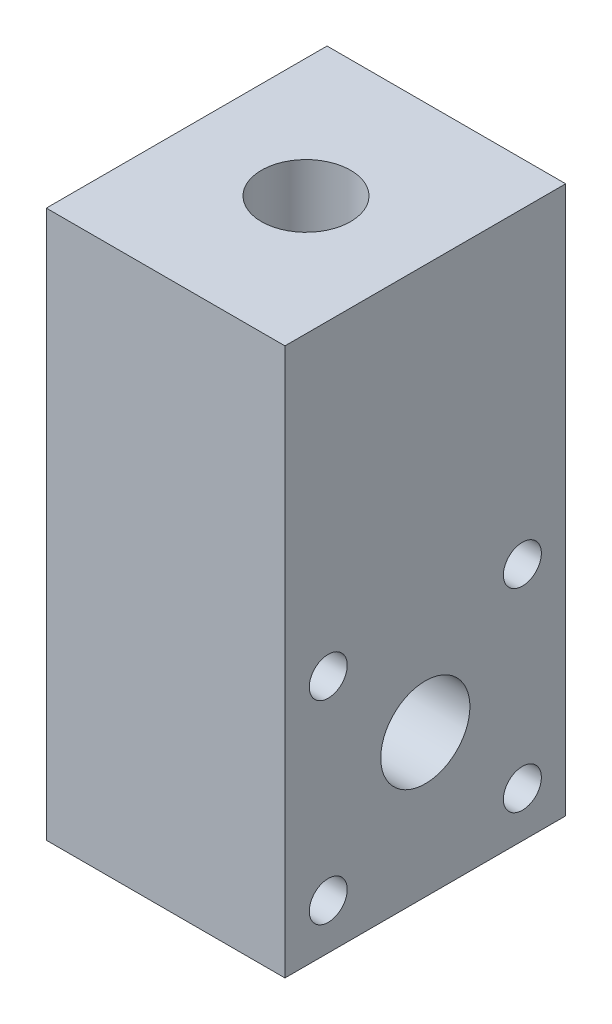
from build123d import *

# Parameters (mm, degrees)
ESQUISSE1_W             = 17
ESQUISSE1_H             = 20
BOSS_EXTRU_1_DEPTH      = 19.5
ESQUISSE2_R             = 3.175
ENL_V_MAT_EXTRU_1_DEPTH = 18
ESQUISSE3_R             = 3.175
ENL_V_MAT_EXTRU_2_DEPTH = 12.7
ESQUISSE4_R             = 1.35255
ENL_V_MAT_EXTRU_3_DEPTH = 18


with BuildPart() as part:
    # Esquisse1 → Boss.-Extru.1 (new body, symmetric)
    with BuildSketch(Plane(origin=(0, 0, 0), x_dir=(1, 0, 0), z_dir=(0, 1, 0))):
        Rectangle(ESQUISSE1_W, ESQUISSE1_H)
    extrude(amount=BOSS_EXTRU_1_DEPTH, both=True)

    # Esquisse2 → Enlèv. mat.-Extru.1 (cut, through all)
    with BuildSketch(Plane.ZY.offset(8.5)):
        with Locations((0, -9.34)):
            Circle(ESQUISSE2_R)
    extrude(amount=-ENL_V_MAT_EXTRU_1_DEPTH, mode=Mode.SUBTRACT)

    # Esquisse3 → Enlèv. mat.-Extru.2 (cut)
    with BuildSketch(Plane(origin=(0, 19.5, 0), x_dir=(1, 0, 0), z_dir=(0, 1, 0))):
        Circle(ESQUISSE3_R)
    extrude(amount=-ENL_V_MAT_EXTRU_2_DEPTH, mode=Mode.SUBTRACT)

    # Esquisse4 → Enlèv. mat.-Extru.3 (cut, through all)
    with BuildSketch(Plane(origin=(8.5, 0, 0), x_dir=(0, 0, -1), z_dir=(1, 0, 0))):
        with Locations((-6.914797213, -2.425202787)):
            Circle(ESQUISSE4_R)
        with Locations((6.914797213, -2.425202787)):
            Circle(ESQUISSE4_R)
        with Locations((-6.914797213, -16.254797213)):
            Circle(ESQUISSE4_R)
        with Locations((6.914797213, -16.254797213)):
            Circle(ESQUISSE4_R)
    extrude(amount=-ENL_V_MAT_EXTRU_3_DEPTH, mode=Mode.SUBTRACT)


solid = part.part
